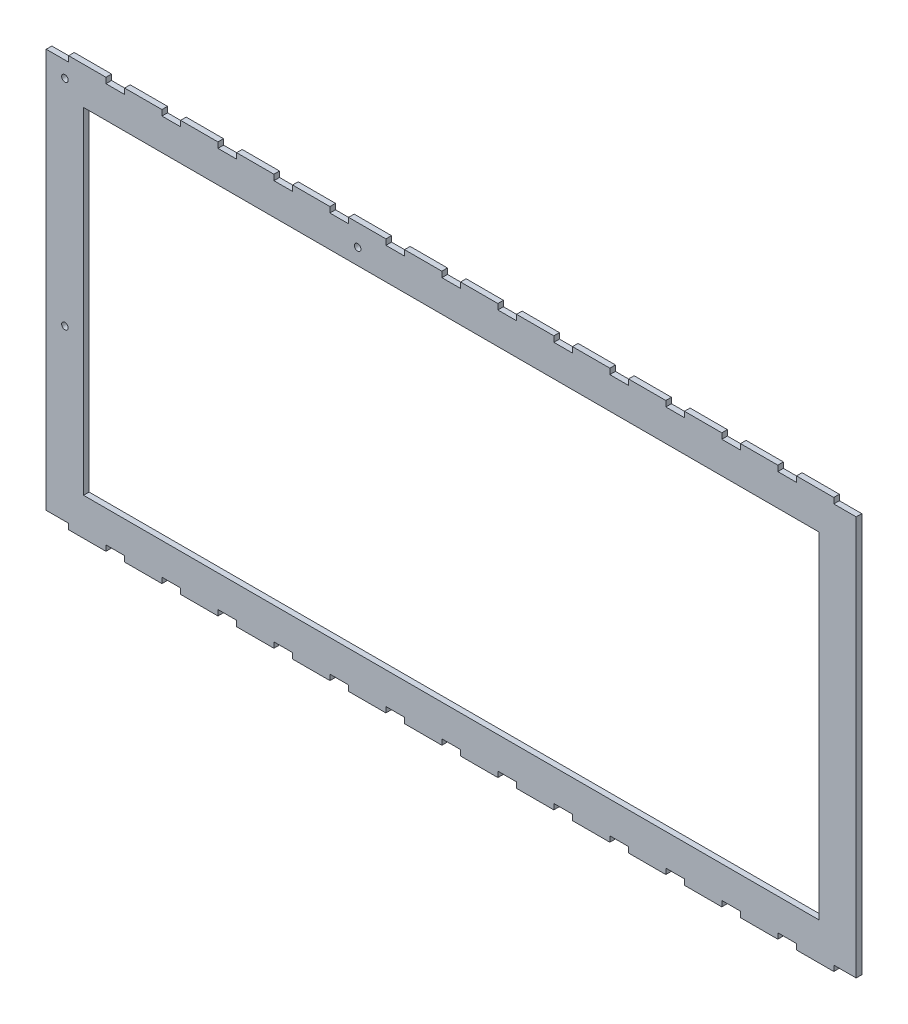
from build123d import *

# Parameters (mm, degrees)
ESQUISSE1_W             = 434
ESQUISSE1_H             = 220
ESQUISSE1_W_2           = 394
ESQUISSE1_H_2           = 180
BOSS_EXTRU_1_DEPTH      = 3
ESQUISSE2_W             = 10
ESQUISSE2_H             = 3
ESQUISSE2_W_2           = 2
ENL_V_MAT_EXTRU_1_DEPTH = 3
ESQUISSE3_R             = 1.75
ENL_V_MAT_EXTRU_2_DEPTH = 3


with BuildPart() as part:
    # Esquisse1 → Boss.-Extru.1 (new body)
    with BuildSketch(Plane.XY):
        Rectangle(ESQUISSE1_W, ESQUISSE1_H)
        Rectangle(ESQUISSE1_W_2, ESQUISSE1_H_2, mode=Mode.SUBTRACT)
    extrude(amount=BOSS_EXTRU_1_DEPTH)

    # Esquisse2 → Enlèv. mat.-Extru.1 (cut)
    with BuildSketch(Plane.XY.offset(3)):
        with Locations((-210, 108.5)):
            Rectangle(ESQUISSE2_W, ESQUISSE2_H)
        with Locations((-180, 108.5)):
            Rectangle(ESQUISSE2_W, ESQUISSE2_H)
        with Locations((-150, 108.5)):
            Rectangle(ESQUISSE2_W, ESQUISSE2_H)
        with Locations((-120, 108.5)):
            Rectangle(ESQUISSE2_W, ESQUISSE2_H)
        with Locations((-90, 108.5)):
            Rectangle(ESQUISSE2_W, ESQUISSE2_H)
        with Locations((-30, 108.5)):
            Rectangle(ESQUISSE2_W, ESQUISSE2_H)
        with Locations((30, 108.5)):
            Rectangle(ESQUISSE2_W, ESQUISSE2_H)
        with Locations((60, 108.5)):
            Rectangle(ESQUISSE2_W, ESQUISSE2_H)
        with Locations((90, 108.5)):
            Rectangle(ESQUISSE2_W, ESQUISSE2_H)
        with Locations((120, 108.5)):
            Rectangle(ESQUISSE2_W, ESQUISSE2_H)
        with Locations((150, 108.5)):
            Rectangle(ESQUISSE2_W, ESQUISSE2_H)
        with Locations((180, 108.5)):
            Rectangle(ESQUISSE2_W, ESQUISSE2_H)
        with Locations((210, 108.5)):
            Rectangle(ESQUISSE2_W, ESQUISSE2_H)
        with Locations((210, -108.5)):
            Rectangle(ESQUISSE2_W, ESQUISSE2_H)
        with Locations((180, -108.5)):
            Rectangle(ESQUISSE2_W, ESQUISSE2_H)
        with Locations((150, -108.5)):
            Rectangle(ESQUISSE2_W, ESQUISSE2_H)
        with Locations((90, -108.5)):
            Rectangle(ESQUISSE2_W, ESQUISSE2_H)
        with Locations((60, -108.5)):
            Rectangle(ESQUISSE2_W, ESQUISSE2_H)
        with Locations((-30, -108.5)):
            Rectangle(ESQUISSE2_W, ESQUISSE2_H)
        with Locations((-60, -108.5)):
            Rectangle(ESQUISSE2_W, ESQUISSE2_H)
        with Locations((-90, -108.5)):
            Rectangle(ESQUISSE2_W, ESQUISSE2_H)
        with Locations((-120, -108.5)):
            Rectangle(ESQUISSE2_W, ESQUISSE2_H)
        with Locations((-150, -108.5)):
            Rectangle(ESQUISSE2_W, ESQUISSE2_H)
        with Locations((-210, -108.5)):
            Rectangle(ESQUISSE2_W, ESQUISSE2_H)
        with Locations((-180, -108.5)):
            Rectangle(ESQUISSE2_W, ESQUISSE2_H)
        with Locations((-216, -108.5)):
            Rectangle(ESQUISSE2_W_2, ESQUISSE2_H)
        with Locations((-216, 108.5)):
            Rectangle(ESQUISSE2_W_2, ESQUISSE2_H)
        with Locations((-60, 108.5)):
            Rectangle(ESQUISSE2_W, ESQUISSE2_H)
        with Locations((0, 108.5)):
            Rectangle(ESQUISSE2_W, ESQUISSE2_H)
        with Locations((120, -108.5)):
            Rectangle(ESQUISSE2_W, ESQUISSE2_H)
        with Locations((30, -108.5)):
            Rectangle(ESQUISSE2_W, ESQUISSE2_H)
        with Locations((0, -108.5)):
            Rectangle(ESQUISSE2_W, ESQUISSE2_H)
        with Locations((216, 108.5)):
            Rectangle(ESQUISSE2_W_2, ESQUISSE2_H)
        with Locations((216, -108.5)):
            Rectangle(ESQUISSE2_W_2, ESQUISSE2_H)
    extrude(amount=-ENL_V_MAT_EXTRU_1_DEPTH, mode=Mode.SUBTRACT)

    # Esquisse3 → Enlèv. mat.-Extru.2 (cut)
    with BuildSketch(Plane.XY.offset(3)):
        with Locations((-207, 98.5)):
            Circle(ESQUISSE3_R)
        with Locations((-50.1, 98.5)):
            Circle(ESQUISSE3_R)
        with Locations((-207, -16.46)):
            Circle(ESQUISSE3_R)
    extrude(amount=-ENL_V_MAT_EXTRU_2_DEPTH, mode=Mode.SUBTRACT)


solid = part.part
